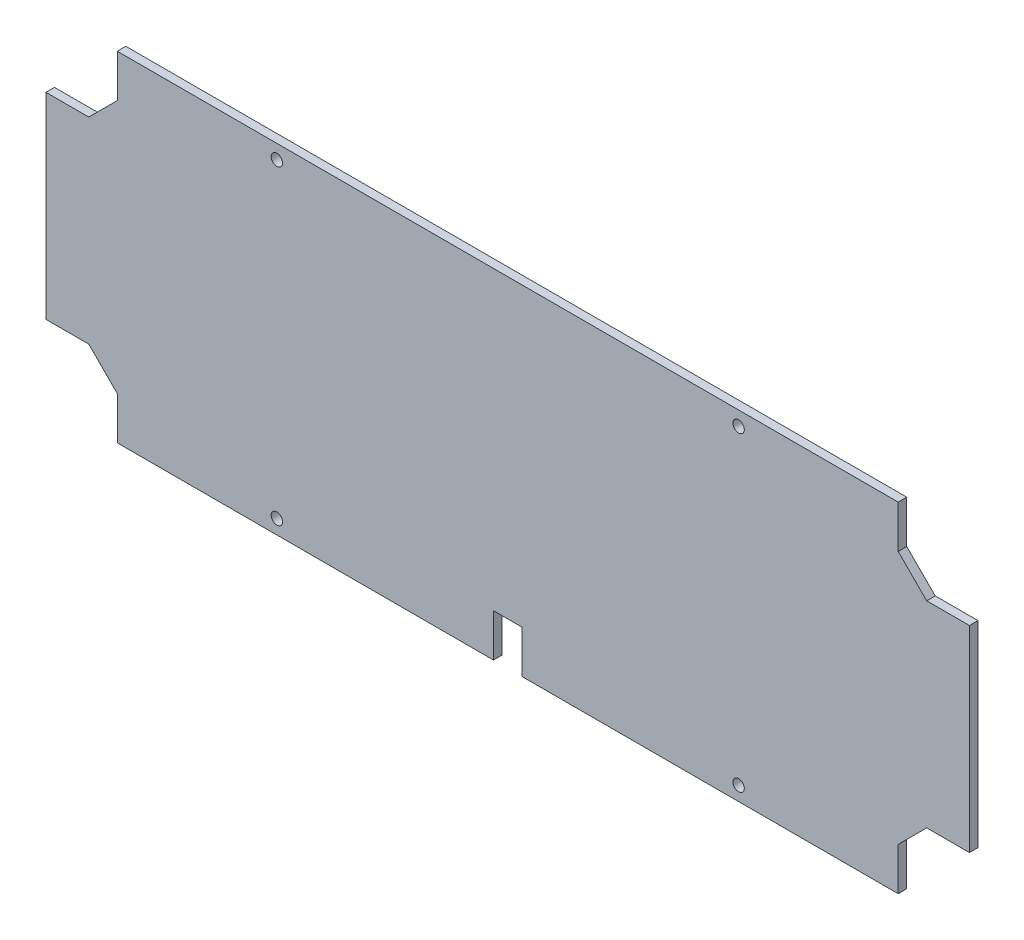
from build123d import *

# Parameters (mm, degrees)
SKETCH2_R           = 2
BOSS_EXTRUDE1_DEPTH = 3
SKETCH3_W           = 5
SKETCH3_H           = 15
CUT_EXTRUDE1_DEPTH  = 3


with BuildPart() as part:
    # Sketch2 → Boss-Extrude1 (new body)
    with BuildSketch(Plane.XY):
        with BuildLine():
            Line((0, 94), (0, 59.5))
            Line((0, 59.5), (162, 59.5))
            Line((162, 59.5), (162, 114))
            Line((162, 114), (83, 114))
            ThreePointArc((83, 114), (81, 112), (79, 114))
            Line((79, 114), (25, 114))
            Line((25, 114), (25, 104))
            Line((25, 104), (15, 94))
            Line((15, 94), (0, 94))
        make_face()
        with BuildLine():
            Line((83, 114), (162, 114))
            Line((162, 114), (162, 119))
            Line((162, 119), (25, 119))
            Line((25, 119), (25, 114))
            Line((25, 114), (79, 114))
            ThreePointArc((79, 114), (81, 116), (83, 114))
        make_face()
        with BuildLine():
            Line((162, 119), (162, 114))
            Line((162, 114), (241, 114))
            ThreePointArc((241, 114), (243, 116), (245, 114))
            Line((245, 114), (299, 114))
            Line((299, 114), (299, 119))
            Line((299, 119), (162, 119))
        make_face()
        with BuildLine():
            Line((162, 114), (162, 59.5))
            Line((162, 59.5), (324, 59.5))
            Line((324, 59.5), (324, 94))
            Line((324, 94), (309, 94))
            Line((309, 94), (299, 104))
            Line((299, 104), (299, 114))
            Line((299, 114), (245, 114))
            ThreePointArc((245, 114), (243, 112), (241, 114))
            Line((241, 114), (162, 114))
        make_face()
        Polygon((162, 59.5), (162, 0), (299, 0), (299, 15), (309, 25), (324, 25), (324, 59.5), align=None)
        with Locations((243, 5)):
            Circle(SKETCH2_R, mode=Mode.SUBTRACT)
        Polygon((25, 15), (25, 0), (162, 0), (162, 59.5), (0, 59.5), (0, 25), (15, 25), align=None)
        with Locations((81, 5)):
            Circle(SKETCH2_R, mode=Mode.SUBTRACT)
    extrude(amount=BOSS_EXTRUDE1_DEPTH)

    # Sketch3 → Cut-Extrude1 (cut)
    with BuildSketch(Plane.XY.offset(3)):
        with Locations((159.5, 7.5)):
            Rectangle(SKETCH3_W, SKETCH3_H)
        with Locations((164.5, 7.5)):
            Rectangle(SKETCH3_W, SKETCH3_H)
    extrude(amount=-CUT_EXTRUDE1_DEPTH, mode=Mode.SUBTRACT)


solid = part.part
